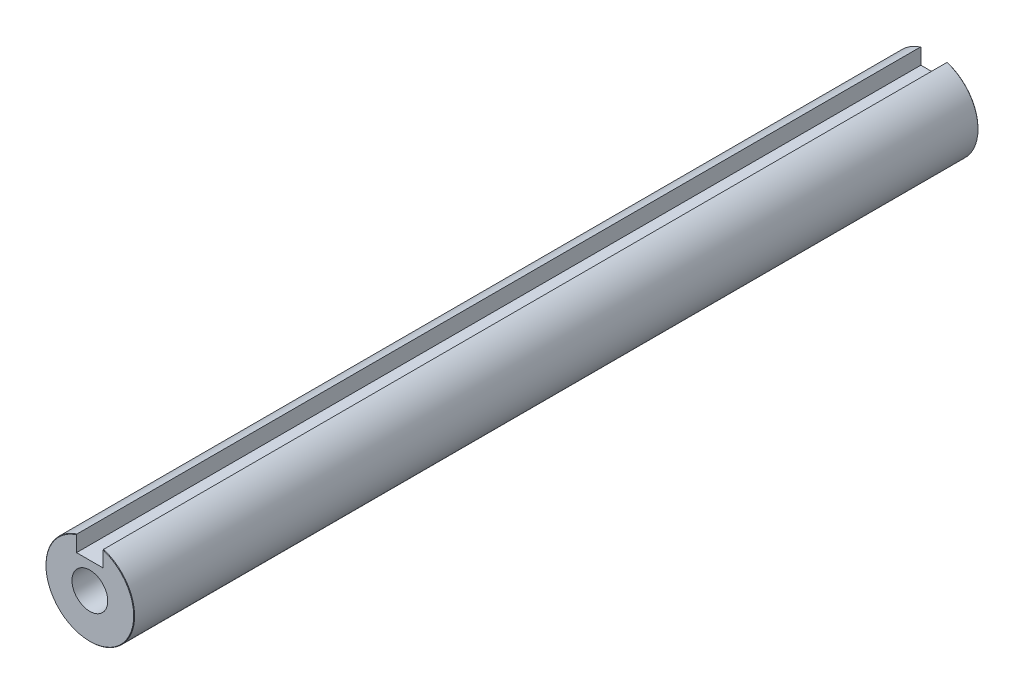
from build123d import *

# Parameters (mm, degrees)
BOSS_EXTRUDE1_DEPTH            = 47.625
BOSS_EXTRUDE1_DEPTH_BACK       = 47.625
CHAMFER1_SIZE                  = 0.05
TAP_DRILL_FOR_10_32_TAP2_D     = 4.0386
TAP_DRILL_FOR_10_32_TAP2_DEPTH = 15.875
TAP_DRILL_FOR_10_32_TAP2_TIP   = 1.213317848
TAP_DRILL_FOR_10_32_TAP1_D     = 4.0386
TAP_DRILL_FOR_10_32_TAP1_DEPTH = 9.525
TAP_DRILL_FOR_10_32_TAP1_TIP   = 1.213317848


with BuildPart() as part:
    # Sketch3 → Boss-Extrude1 (new, two sides: drawn at the far end of the back side and taken through both)
    with BuildSketch(Plane.XY.offset(-BOSS_EXTRUDE1_DEPTH_BACK)):
        with BuildLine():
            Line((-1.5, 2.969696007), (-1.5, 4.769696007))
            ThreePointArc((-1.5, 4.769696007), (0, -5), (1.5, 4.769696007))
            Line((1.5, 4.769696007), (1.5, 2.969696007))
            Line((1.5, 2.969696007), (-1.5, 2.969696007))
        make_face()
    extrude(amount=BOSS_EXTRUDE1_DEPTH + BOSS_EXTRUDE1_DEPTH_BACK)

    # Chamfer1
    chamfer1_edges = [part.edges().sort_by_distance(p)[0] for p in [
        (0, -5, -47.625),
        (0, -5, 47.625),
    ]]
    chamfer(chamfer1_edges, length=CHAMFER1_SIZE)

    # Tap Drill for #10-32 Tap2
    with Locations(Plane(origin=(0, 0, -47.625), x_dir=(-1, 0, 0), z_dir=(0, 0, -1))):
        with Locations((0, 0)):
            Hole(TAP_DRILL_FOR_10_32_TAP2_D / 2, depth=TAP_DRILL_FOR_10_32_TAP2_DEPTH)
            with Locations((0, 0, -(TAP_DRILL_FOR_10_32_TAP2_DEPTH + TAP_DRILL_FOR_10_32_TAP2_TIP / 2))):  # 118° drill point
                Cone(0, TAP_DRILL_FOR_10_32_TAP2_D / 2, TAP_DRILL_FOR_10_32_TAP2_TIP, mode=Mode.SUBTRACT)

    # Tap Drill for #10-32 Tap1
    with Locations(Plane.XY.offset(47.625)):
        with Locations((0, 0)):
            Hole(TAP_DRILL_FOR_10_32_TAP1_D / 2, depth=TAP_DRILL_FOR_10_32_TAP1_DEPTH)
            with Locations((0, 0, -(TAP_DRILL_FOR_10_32_TAP1_DEPTH + TAP_DRILL_FOR_10_32_TAP1_TIP / 2))):  # 118° drill point
                Cone(0, TAP_DRILL_FOR_10_32_TAP1_D / 2, TAP_DRILL_FOR_10_32_TAP1_TIP, mode=Mode.SUBTRACT)


solid = part.part
